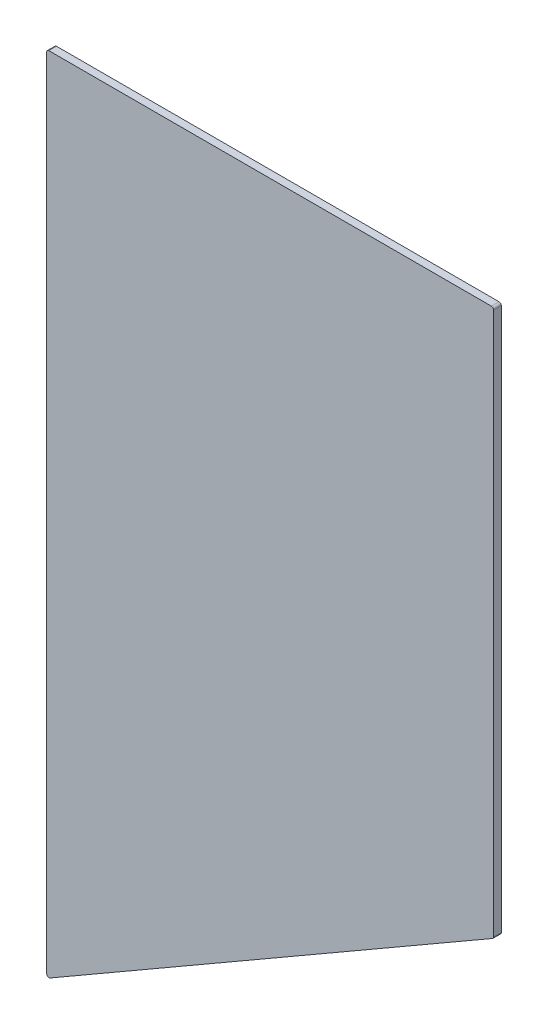
from build123d import *

# Parameters (mm, degrees)
SKETCH1_W           = 254
SKETCH1_H           = 457.2
BOSS_EXTRUDE1_DEPTH = 4.3434
CUT_EXTRUDE3_DEPTH  = 5.3434
FILLET2_R           = 1.27


with BuildPart() as part:
    # Sketch1 → Boss-Extrude1 (new body)
    with BuildSketch(Plane.XY):
        Rectangle(SKETCH1_W, SKETCH1_H)
    extrude(amount=BOSS_EXTRUDE1_DEPTH)

    # Sketch4 → Cut-Extrude3 (cut, through all)
    with BuildSketch(Plane.XY.offset(4.3434)):
        Polygon((-127, -228.6), (127, -81.953031626), (127, -228.6), align=None)
    extrude(amount=-CUT_EXTRUDE3_DEPTH, mode=Mode.SUBTRACT)

    # Fillet2
    fillet2_edges = [part.edges().sort_by_distance(p)[0] for p in [
        (127, -81.953031626, 2.1717),
        (-127, -228.6, 2.1717),
        (-127, 228.6, 2.1717),
        (127, 228.6, 2.1717),
    ]]
    fillet(fillet2_edges, radius=FILLET2_R)


solid = part.part
